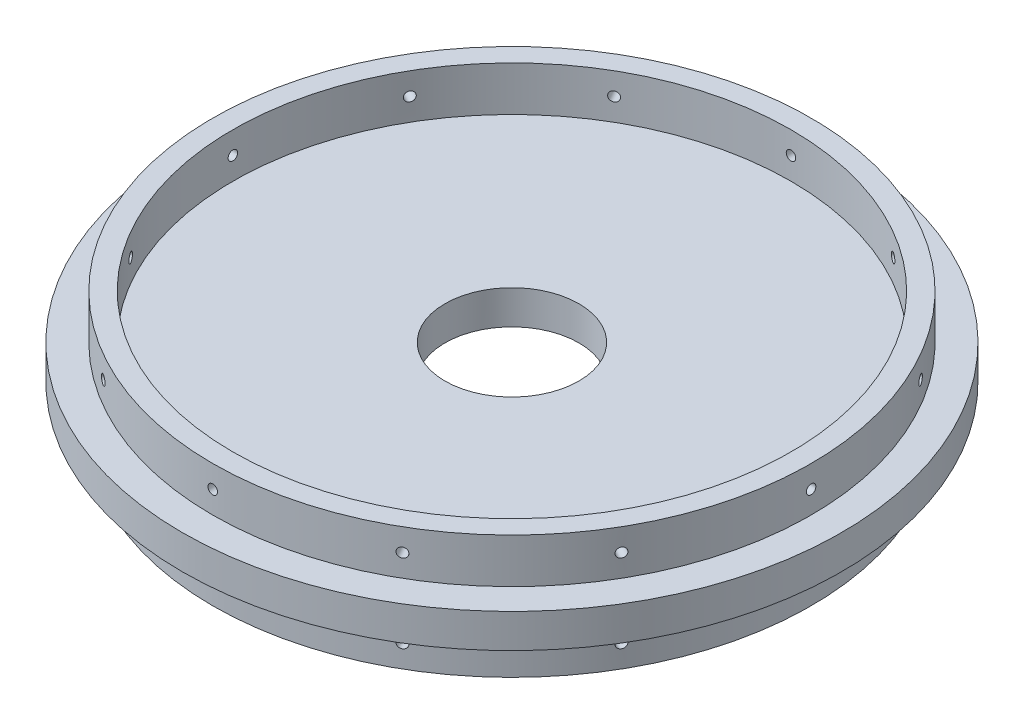
from build123d import *

# Parameters (mm, degrees)
SKETCH1_R                = 93.726
BOSS_EXTRUDE1_DEPTH      = 4.826
SKETCH4_R                = 85.09
SKETCH4_R_2              = 79.375
BOSS_EXTRUDE2_DEPTH      = 12.7
SKETCH5_R                = 1.35255
CUT_EXTRUDE2_DEPTH       = 12.7
CIRPATTERN1_COUNT        = 12
MIRROR2_COPY_1_SKETCH_R  = 1.35255
MIRROR2_COPY_1_DEPTH     = 12.7
MIRROR2_COPY_2_SKETCH_R  = 1.35255
MIRROR2_COPY_2_DEPTH     = 12.7
MIRROR2_COPY_3_SKETCH_R  = 1.35255
MIRROR2_COPY_3_DEPTH     = 12.7
MIRROR2_COPY_4_SKETCH_R  = 1.35255
MIRROR2_COPY_4_DEPTH     = 12.7
MIRROR2_COPY_5_SKETCH_R  = 1.35255
MIRROR2_COPY_5_DEPTH     = 12.7
MIRROR2_COPY_6_SKETCH_R  = 1.35255
MIRROR2_COPY_6_DEPTH     = 12.7
MIRROR2_COPY_7_SKETCH_R  = 1.35255
MIRROR2_COPY_7_DEPTH     = 12.7
MIRROR2_COPY_8_SKETCH_R  = 1.35255
MIRROR2_COPY_8_DEPTH     = 12.7
MIRROR2_COPY_9_SKETCH_R  = 1.35255
MIRROR2_COPY_9_DEPTH     = 12.7
MIRROR2_COPY_10_SKETCH_R = 1.35255
MIRROR2_COPY_10_DEPTH    = 12.7
MIRROR2_COPY_11_SKETCH_R = 1.35255
MIRROR2_COPY_11_DEPTH    = 12.7
SKETCH7_R                = 19.05
CUT_EXTRUDE4_DEPTH       = 135.420006176


with BuildPart() as part:
    # Sketch1 → Boss-Extrude1 (new, symmetric)
    with BuildSketch(Plane(origin=(0, 0, 0), x_dir=(1, 0, 0), z_dir=(0, 1, 0))):
        with Locations(Location((0, 0, 0), (0, 0, 270))):
            Circle(SKETCH1_R)
    extrude(amount=BOSS_EXTRUDE1_DEPTH, both=True)

    # Sketch4 → Boss-Extrude2 (add)
    with BuildSketch(Plane(origin=(0, 4.826, 0), x_dir=(1, 0, 0), z_dir=(0, 1, 0))):
        with Locations(Location((0, 0, 0), (0, 0, 270))):
            Circle(SKETCH4_R)
        with Locations(Location((0, 0, 0), (0, 0, 270))):
            Circle(SKETCH4_R_2, mode=Mode.SUBTRACT)
    boss_extrude2 = extrude(amount=BOSS_EXTRUDE2_DEPTH)

    # Sketch5 → Cut-Extrude2 (cut)
    with BuildSketch(Plane(origin=(0, 0, -85.09), x_dir=(-1, 0, 0), z_dir=(0, 0, -1))):
        with Locations(Location((0, 11.176, 0), (0, 0, 90))):
            Circle(SKETCH5_R)
    cut_extrude2 = extrude(amount=-CUT_EXTRUDE2_DEPTH, mode=Mode.SUBTRACT)

    # CirPattern1: Cut-Extrude2 ×12 about axis
    cirpattern1_axis = Axis((0, 17.526, 0), (0, -1, 0))
    for i in range(1, CIRPATTERN1_COUNT):
        add(cut_extrude2.rotate(cirpattern1_axis, i * 360 / CIRPATTERN1_COUNT), mode=Mode.SUBTRACT)

    # Mirror2: Boss-Extrude2, Cut-Extrude2 across plane
    add(boss_extrude2.mirror(Plane.ZX))
    add(cut_extrude2.mirror(Plane.ZX), mode=Mode.SUBTRACT)

    # Mirror2 copy 1 sketch → Mirror2 copy 1 (cut)
    with BuildSketch(Plane(origin=(42.545, 0, -73.690101608), x_dir=(-0.8660254037844387, 0, -0.49999999999999994), z_dir=(0.49999999999999994, 0, -0.8660254037844387))):
        with Locations((0, -11.176)):
            Circle(MIRROR2_COPY_1_SKETCH_R)
    extrude(amount=-MIRROR2_COPY_1_DEPTH, mode=Mode.SUBTRACT)

    # Mirror2 copy 2 sketch → Mirror2 copy 2 (cut)
    with BuildSketch(Plane(origin=(73.690101608, 0, -42.545), x_dir=(-0.5000000000000001, 0, -0.8660254037844386), z_dir=(0.8660254037844386, 0, -0.5000000000000001))):
        with Locations((0, -11.176)):
            Circle(MIRROR2_COPY_2_SKETCH_R)
    extrude(amount=-MIRROR2_COPY_2_DEPTH, mode=Mode.SUBTRACT)

    # Mirror2 copy 3 sketch → Mirror2 copy 3 (cut)
    with BuildSketch(Plane(origin=(85.09, 0, 0), x_dir=(0, 0, -1), z_dir=(1, 0, 0))):
        with Locations((0, -11.176)):
            Circle(MIRROR2_COPY_3_SKETCH_R)
    extrude(amount=-MIRROR2_COPY_3_DEPTH, mode=Mode.SUBTRACT)

    # Mirror2 copy 4 sketch → Mirror2 copy 4 (cut)
    with BuildSketch(Plane(origin=(73.690101608, 0, 42.545), x_dir=(0.4999999999999998, 0, -0.8660254037844387), z_dir=(0.8660254037844387, 0, 0.4999999999999998))):
        with Locations((0, -11.176)):
            Circle(MIRROR2_COPY_4_SKETCH_R)
    extrude(amount=-MIRROR2_COPY_4_DEPTH, mode=Mode.SUBTRACT)

    # Mirror2 copy 5 sketch → Mirror2 copy 5 (cut)
    with BuildSketch(Plane(origin=(42.545, 0, 73.690101608), x_dir=(0.8660254037844387, 0, -0.49999999999999994), z_dir=(0.49999999999999994, 0, 0.8660254037844387))):
        with Locations((0, -11.176)):
            Circle(MIRROR2_COPY_5_SKETCH_R)
    extrude(amount=-MIRROR2_COPY_5_DEPTH, mode=Mode.SUBTRACT)

    # Mirror2 copy 6 sketch → Mirror2 copy 6 (cut)
    with BuildSketch(Plane.XY.offset(85.09)):
        with Locations((0, -11.176)):
            Circle(MIRROR2_COPY_6_SKETCH_R)
    extrude(amount=-MIRROR2_COPY_6_DEPTH, mode=Mode.SUBTRACT)

    # Mirror2 copy 7 sketch → Mirror2 copy 7 (cut)
    with BuildSketch(Plane(origin=(-42.545, 0, 73.690101608), x_dir=(0.8660254037844386, 0, 0.5000000000000001), z_dir=(-0.5000000000000001, 0, 0.8660254037844386))):
        with Locations((0, -11.176)):
            Circle(MIRROR2_COPY_7_SKETCH_R)
    extrude(amount=-MIRROR2_COPY_7_DEPTH, mode=Mode.SUBTRACT)

    # Mirror2 copy 8 sketch → Mirror2 copy 8 (cut)
    with BuildSketch(Plane(origin=(-73.690101608, 0, 42.545), x_dir=(0.5000000000000004, 0, 0.8660254037844384), z_dir=(-0.8660254037844384, 0, 0.5000000000000004))):
        with Locations((0, -11.176)):
            Circle(MIRROR2_COPY_8_SKETCH_R)
    extrude(amount=-MIRROR2_COPY_8_DEPTH, mode=Mode.SUBTRACT)

    # Mirror2 copy 9 sketch → Mirror2 copy 9 (cut)
    with BuildSketch(Plane.ZY.offset(85.09)):
        with Locations((0, -11.176)):
            Circle(MIRROR2_COPY_9_SKETCH_R)
    extrude(amount=-MIRROR2_COPY_9_DEPTH, mode=Mode.SUBTRACT)

    # Mirror2 copy 10 sketch → Mirror2 copy 10 (cut)
    with BuildSketch(Plane(origin=(-73.690101608, 0, -42.545), x_dir=(-0.5000000000000001, 0, 0.8660254037844386), z_dir=(-0.8660254037844386, 0, -0.5000000000000001))):
        with Locations((0, -11.176)):
            Circle(MIRROR2_COPY_10_SKETCH_R)
    extrude(amount=-MIRROR2_COPY_10_DEPTH, mode=Mode.SUBTRACT)

    # Mirror2 copy 11 sketch → Mirror2 copy 11 (cut)
    with BuildSketch(Plane(origin=(-42.545, 0, -73.690101608), x_dir=(-0.8660254037844384, 0, 0.5000000000000004), z_dir=(-0.5000000000000004, 0, -0.8660254037844384))):
        with Locations((0, -11.176)):
            Circle(MIRROR2_COPY_11_SKETCH_R)
    extrude(amount=-MIRROR2_COPY_11_DEPTH, mode=Mode.SUBTRACT)

    # Sketch7 → Cut-Extrude4 (cut, through all)
    with BuildSketch(Plane.XZ.offset(4.826)):
        with Locations(Location((0, 0, 0), (0, 0, 270))):
            Circle(SKETCH7_R)
    extrude(amount=-CUT_EXTRUDE4_DEPTH, mode=Mode.SUBTRACT)


solid = part.part
